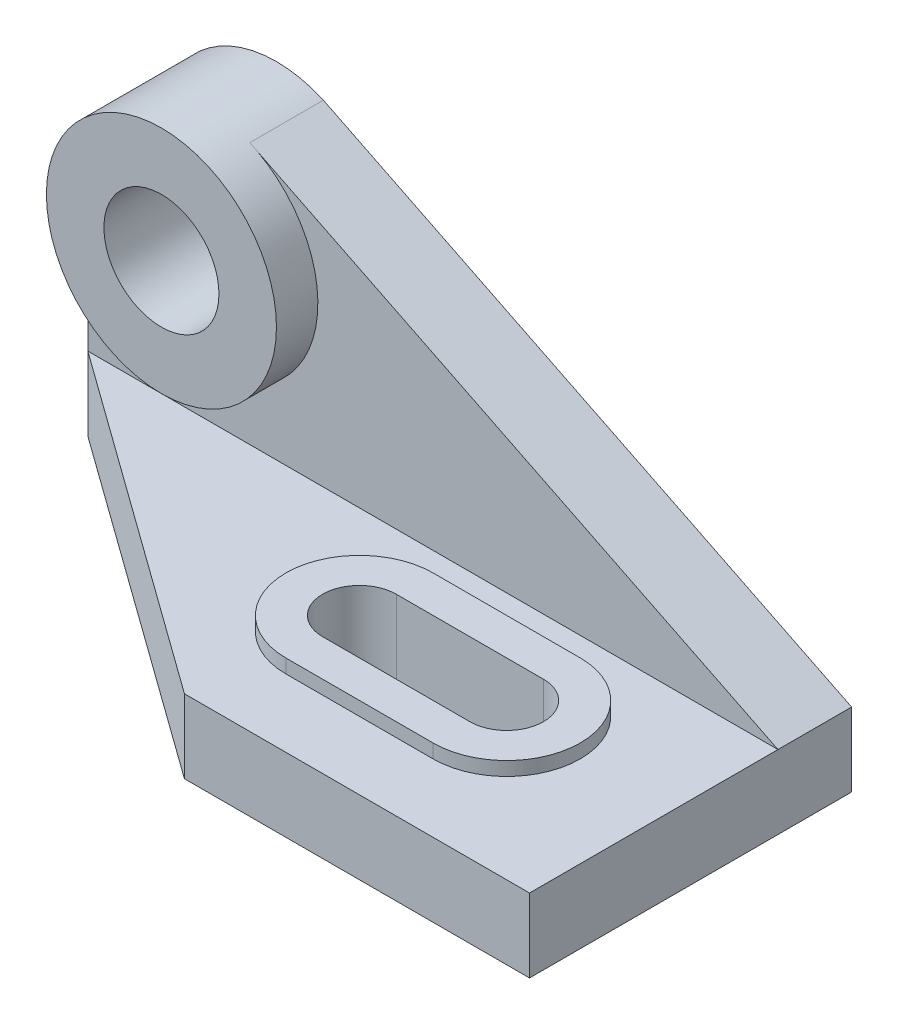
from build123d import *

# Parameters (mm, degrees)
SKETCH1_R           = 12.5
SKETCH1_W           = 150
SKETCH1_H           = 16
BOSS_EXTRUDE4_DEPTH = 16
SKETCH6_R           = 25
SKETCH6_R_2         = 12.5
BOSS_EXTRUDE5_DEPTH = 9
BOSS_EXTRUDE6_DEPTH = 16
CUT_EXTRUDE2_DEPTH  = 17
BOSS_EXTRUDE7_DEPTH = 3
CUT_EXTRUDE6_DEPTH  = 60


with BuildPart() as part:
    # Sketch1 → Boss-Extrude4 (new body)
    with BuildSketch(Plane.XY):
        with BuildLine():
            ThreePointArc((-31.360767673, 56.826225363), (-55.160209154, 54.975058449), (-66.55701383, 34))
            ThreePointArc((-66.55701383, 34), (-41.55701383, 9), (-16.55701383, 34))
            ThreePointArc((-16.55701383, 34), (-20.060743341, 46.763634086), (-29.589842236, 55.949642459))
            Line((-29.589842236, 55.949642459), (-31.360767673, 56.826225363))
        make_face()
        with Locations((-41.55701383, 34)):
            Circle(SKETCH1_R, mode=Mode.SUBTRACT)
        with BuildLine():
            Line((-66.55701383, 34), (-66.55701383, 0))
            Line((-66.55701383, 0), (83.44298617, 0))
            Line((83.44298617, 0), (-29.589842236, 55.949642459))
            ThreePointArc((-29.589842236, 55.949642459), (-20.060743341, 46.763634086), (-16.55701383, 34))
            ThreePointArc((-16.55701383, 34), (-41.55701383, 9), (-66.55701383, 34))
        make_face()
        with Locations((8.44298617, -8)):
            Rectangle(SKETCH1_W, SKETCH1_H)
    extrude(amount=BOSS_EXTRUDE4_DEPTH)

    # Sketch6 → Boss-Extrude5 (add)
    with BuildSketch(Plane.XY.offset(16)):
        with Locations((-41.55701383, 34)):
            Circle(SKETCH6_R)
        with Locations((-41.55701383, 34)):
            Circle(SKETCH6_R_2, mode=Mode.SUBTRACT)
    extrude(amount=BOSS_EXTRUDE5_DEPTH)

    # Sketch7 → Boss-Extrude6 (add)
    with BuildSketch(Plane.XZ.offset(16)):
        Polygon((83.44298617, 16), (83.44298617, 70), (8.44298617, 70), (-66.55701383, 16), align=None)
    extrude(amount=-BOSS_EXTRUDE6_DEPTH)

    # Sketch8 → Cut-Extrude2 (cut, through all)
    with BuildSketch(Plane(origin=(0, 0, 0), x_dir=(1, 0, 0), z_dir=(0, 1, 0))):
        with BuildLine():
            Line((47.721749713, -47.241556866), (15.721749713, -47.241556866))
            ThreePointArc((15.721749713, -47.241556866), (7.721749713, -39.241556866), (15.721749713, -31.241556866))
            Line((15.721749713, -31.241556866), (47.721749713, -31.241556866))
            ThreePointArc((47.721749713, -31.241556866), (55.721749713, -39.241556866), (47.721749713, -47.241556866))
        make_face()
    extrude(amount=-CUT_EXTRUDE2_DEPTH, mode=Mode.SUBTRACT)

    # Sketch9 → Boss-Extrude7 (add)
    with BuildSketch(Plane(origin=(0, 0, 0), x_dir=(1, 0, 0), z_dir=(0, 1, 0))):
        with BuildLine():
            Line((47.721749713, -55.241556866), (15.721749713, -55.241556866))
            ThreePointArc((15.721749713, -55.241556866), (-0.278250287, -39.241556866), (15.721749713, -23.241556866))
            Line((15.721749713, -23.241556866), (47.721749713, -23.241556866))
            ThreePointArc((47.721749713, -23.241556866), (63.721749713, -39.241556866), (47.721749713, -55.241556866))
        make_face()
    extrude(amount=BOSS_EXTRUDE7_DEPTH)

    # Sketch10 → Cut-Extrude6 (cut, through all)
    with BuildSketch(Plane(origin=(0, 0, 0), x_dir=(1, 0, 0), z_dir=(0, 1, 0))):
        with BuildLine():
            Line((47.721749713, -47.241556866), (15.721749713, -47.241556866))
            ThreePointArc((15.721749713, -47.241556866), (7.721749713, -39.241556866), (15.721749713, -31.241556866))
            Line((15.721749713, -31.241556866), (47.721749713, -31.241556866))
            ThreePointArc((47.721749713, -31.241556866), (55.721749713, -39.241556866), (47.721749713, -47.241556866))
        make_face()
    extrude(amount=CUT_EXTRUDE6_DEPTH, mode=Mode.SUBTRACT)


solid = part.part
